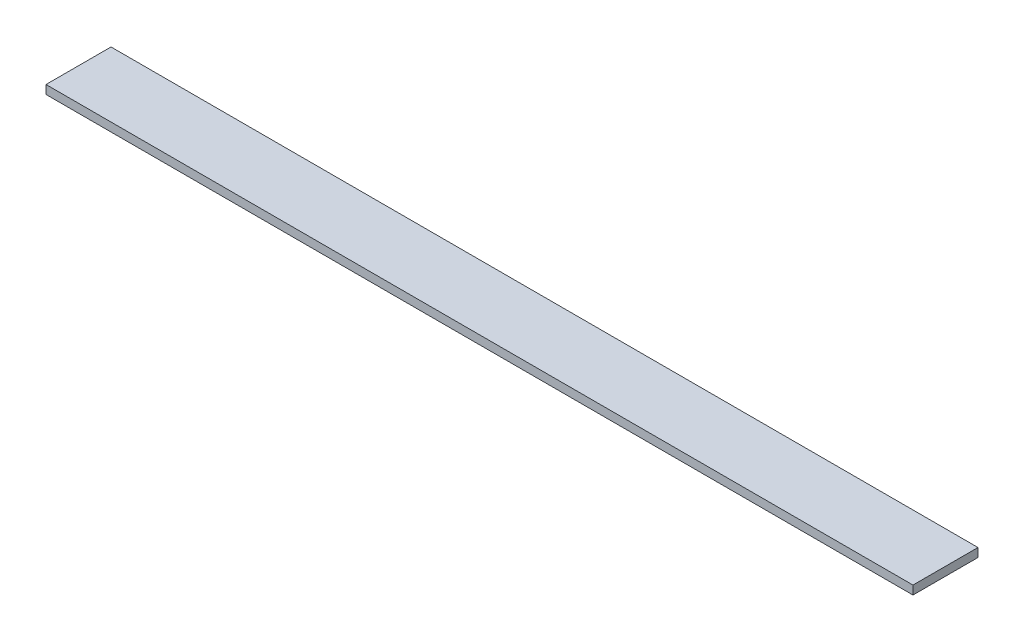
from build123d import *

# Parameters (mm, degrees)
SKETCH_1_W      = 30
SKETCH_1_H      = 4
EXTRUDE_1_DEPTH = 400


with BuildPart() as part:
    # Эскиз1 → Бобышка-Вытянуть1 (new body)
    with BuildSketch(Plane(origin=(0, 0, 0), x_dir=(0, 0, -1), z_dir=(1, 0, 0))):
        Rectangle(SKETCH_1_W, SKETCH_1_H)
    extrude(amount=EXTRUDE_1_DEPTH)


solid = part.part
